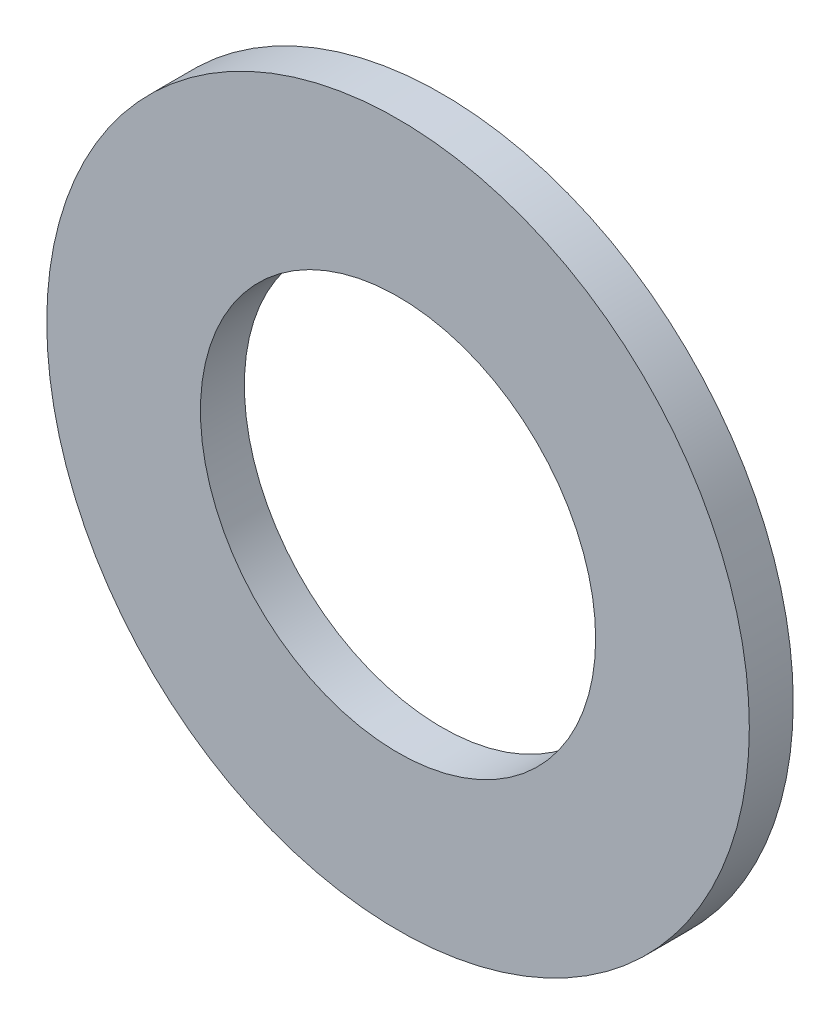
from build123d import *

# Parameters (mm, degrees)
SKETCH1_R           = 8
BOSS_EXTRUDE1_DEPTH = 1
SKETCH2_R           = 4.5
CUT_EXTRUDE1_DEPTH  = 1


with BuildPart() as part:
    # Sketch1 → Boss-Extrude1 (new body)
    with BuildSketch(Plane.XY):
        with Locations((-31.171912812, 18.672051936)):
            Circle(SKETCH1_R)
    extrude(amount=BOSS_EXTRUDE1_DEPTH)

    # Sketch2 → Cut-Extrude1 (cut)
    with BuildSketch(Plane.XY.offset(1)):
        with Locations((-31.171912812, 18.672051936)):
            Circle(SKETCH2_R)
    extrude(amount=-CUT_EXTRUDE1_DEPTH, mode=Mode.SUBTRACT)


solid = part.part
